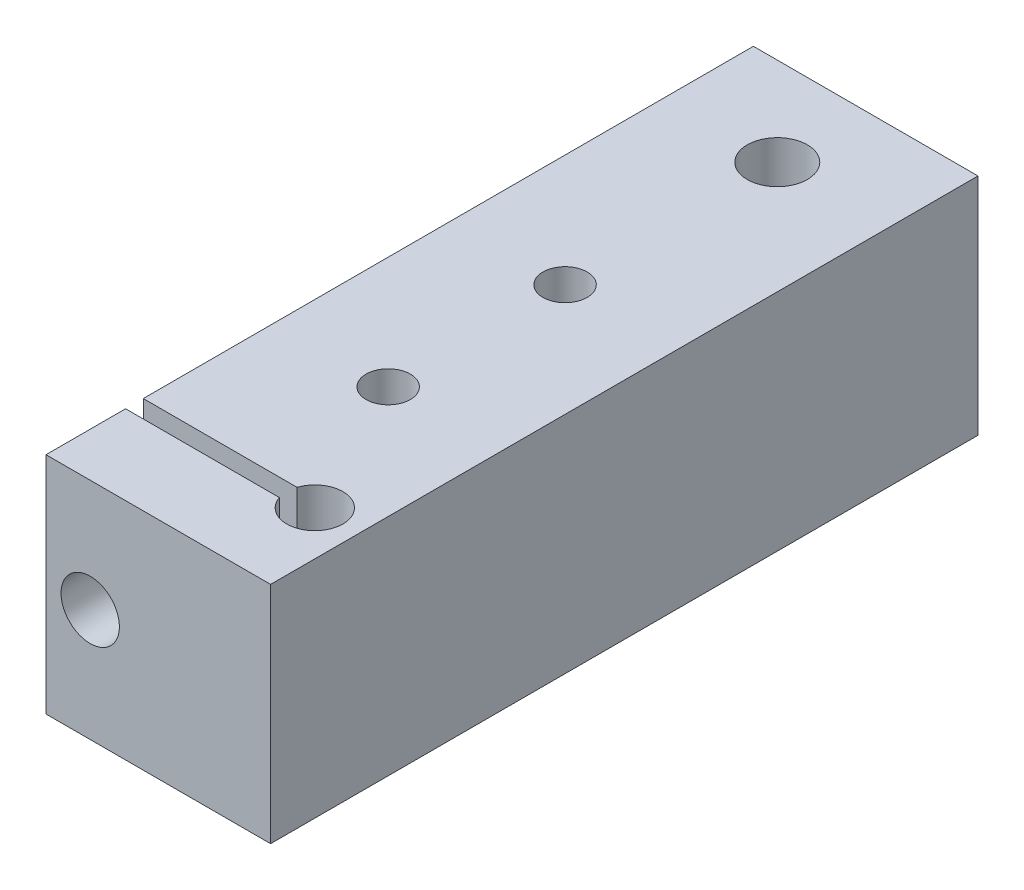
from build123d import *

# Parameters (mm, degrees)
SKETCH1_W                   = 25.4
SKETCH1_H                   = 80
BOSS_EXTRUDE1_DEPTH         = 25.4
F_1_4_0_25_DIAMETER_HOLE1_D = 6.35
SKETCH4_W                   = 20.4
SKETCH4_H                   = 2
CUT_EXTRUDE1_DEPTH          = 88.694469609
M6_CLEARANCE_HOLE1_REACH    = 89.694
M6_CLEARANCE_HOLE1_BORE_R   = 3.3
M6X1_0_TAPPED_HOLE1_D       = 5
M6X1_0_TAPPED_HOLE1_DEPTH   = 17
M6X1_0_TAPPED_HOLE1_TIP     = 1.502151548
M8X1_25_TAPPED_HOLE1_D      = 6.8
M6X1_0_TAPPED_HOLE2_D       = 5


with BuildPart() as part:
    # Sketch1 → Boss-Extrude1 (new body)
    with BuildSketch(Plane(origin=(0, 0, 0), x_dir=(1, 0, 0), z_dir=(0, 1, 0))):
        with Locations((12.7, 40)):
            Rectangle(SKETCH1_W, SKETCH1_H)
    extrude(amount=BOSS_EXTRUDE1_DEPTH)

    # 1/4 (0.25) Diameter Hole1 (through all)
    with Locations(Plane(origin=(0, 25.4, 0), x_dir=(1, 0, 0), z_dir=(0, 1, 0))):
        with Locations((20.4, 10)):
            Hole(F_1_4_0_25_DIAMETER_HOLE1_D / 2)

    # Sketch4 → Cut-Extrude1 (cut, through all)
    with BuildSketch(Plane(origin=(0, 25.4, 0), x_dir=(1, 0, 0), z_dir=(0, 1, 0))):
        with Locations((10.2, 10)):
            Rectangle(SKETCH4_W, SKETCH4_H)
    extrude(amount=-CUT_EXTRUDE1_DEPTH, mode=Mode.SUBTRACT)

    # M6 Clearance Hole1 bore → M6 Clearance Hole1 (cut, up to next)
    with BuildSketch(Plane.XY, mode=Mode.PRIVATE) as m6_clearance_hole1_sk1:
        with Locations((5, 12.7)):
            Circle(M6_CLEARANCE_HOLE1_BORE_R)
    m6_clearance_hole1_tool1 = extrude(m6_clearance_hole1_sk1.sketch, amount=-M6_CLEARANCE_HOLE1_REACH, mode=Mode.PRIVATE) & part.part
    add(m6_clearance_hole1_tool1.solids().sort_by_distance((5, 12.7, 0))[0], mode=Mode.SUBTRACT)

    # M6x1.0 Tapped Hole1
    with Locations(Plane.XY.offset(-11)):
        with Locations((5, 12.7)):
            Hole(M6X1_0_TAPPED_HOLE1_D / 2, depth=M6X1_0_TAPPED_HOLE1_DEPTH)
            with Locations((0, 0, -(M6X1_0_TAPPED_HOLE1_DEPTH + M6X1_0_TAPPED_HOLE1_TIP / 2))):  # 118° drill point
                Cone(0, M6X1_0_TAPPED_HOLE1_D / 2, M6X1_0_TAPPED_HOLE1_TIP, mode=Mode.SUBTRACT)

    # M8x1.25 Tapped Hole1 (through all)
    with Locations(Plane(origin=(0, 25.4, 0), x_dir=(1, 0, 0), z_dir=(0, 1, 0))):
        with Locations((12.7, 70)):
            Hole(M8X1_25_TAPPED_HOLE1_D / 2)

    # M6x1.0 Tapped Hole2 (through all)
    with Locations(Plane(origin=(0, 0, 0), x_dir=(-1, 0, 0), z_dir=(0, -1, 0))):
        with Locations((-12.7, 26), (-12.7, 46)):
            Hole(M6X1_0_TAPPED_HOLE2_D / 2)


solid = part.part
